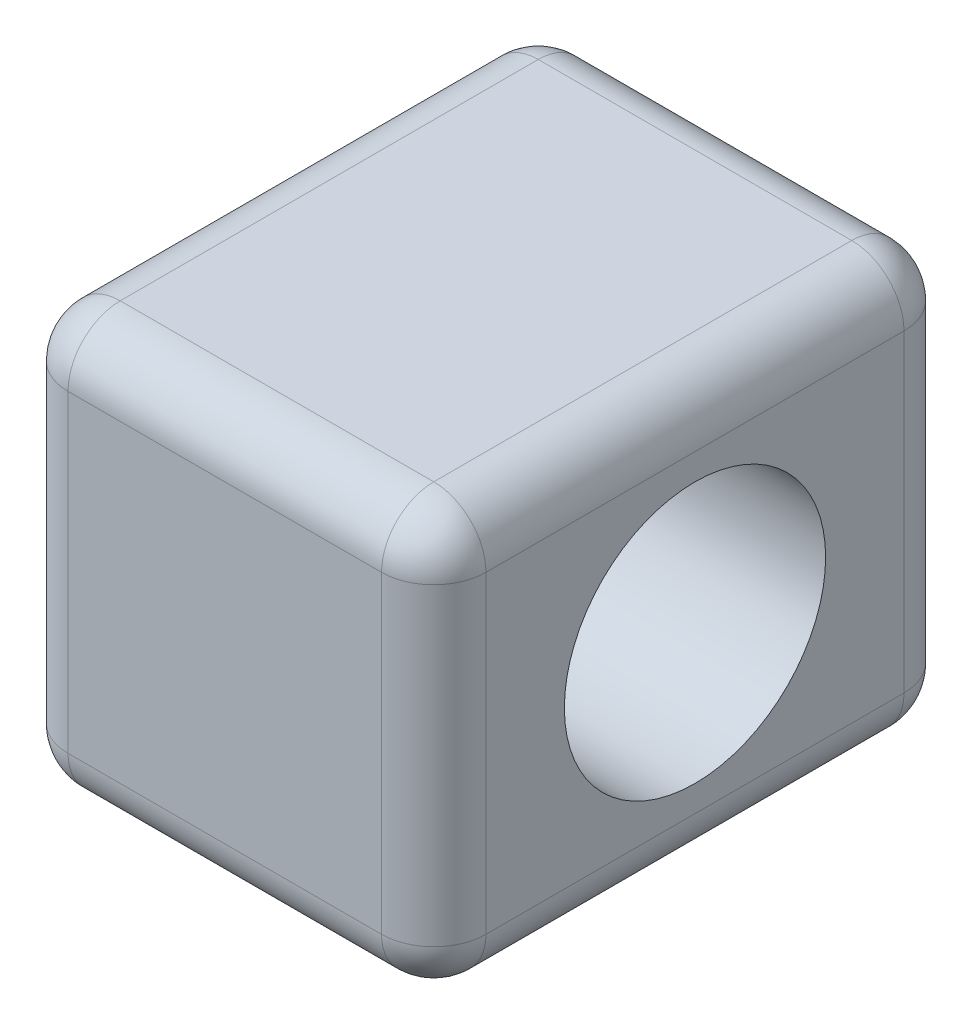
from build123d import *

# Parameters (mm, degrees)
SKETCH_1_W          = 8
SKETCH_1_H          = 8
EXTRUDE_1_DEPTH     = 10
SKETCH_4_R          = 2.5
CUT_EXTRUDE_2_DEPTH = 9
FILLET_1_R          = 1


with BuildPart() as part:
    # 草图1 → 凸台-拉伸1 (new body)
    with BuildSketch(Plane.XY):
        with Locations((4, 4)):
            Rectangle(SKETCH_1_W, SKETCH_1_H)
    extrude(amount=EXTRUDE_1_DEPTH)

    # 草图4 → 切除-拉伸2 (cut, through all)
    with BuildSketch(Plane(origin=(8, 0, 0), x_dir=(0, 0, -1), z_dir=(1, 0, 0))):
        with Locations((-5, 4)):
            Circle(SKETCH_4_R)
    extrude(amount=-CUT_EXTRUDE_2_DEPTH, mode=Mode.SUBTRACT)

    # 圆角1
    fillet_1_edges = [part.edges().sort_by_distance(p)[0] for p in [
        (8, 4, 10),
        (4, 8, 10),
        (0, 4, 10),
        (4, 8, 0),
        (8, 4, 0),
        (4, 0, 0),
        (0, 4, 0),
        (0, 8, 5),
        (8, 8, 5),
        (8, 0, 5),
        (0, 0, 5),
        (4, 0, 10),
    ]]
    fillet(fillet_1_edges, radius=FILLET_1_R)


solid = part.part
